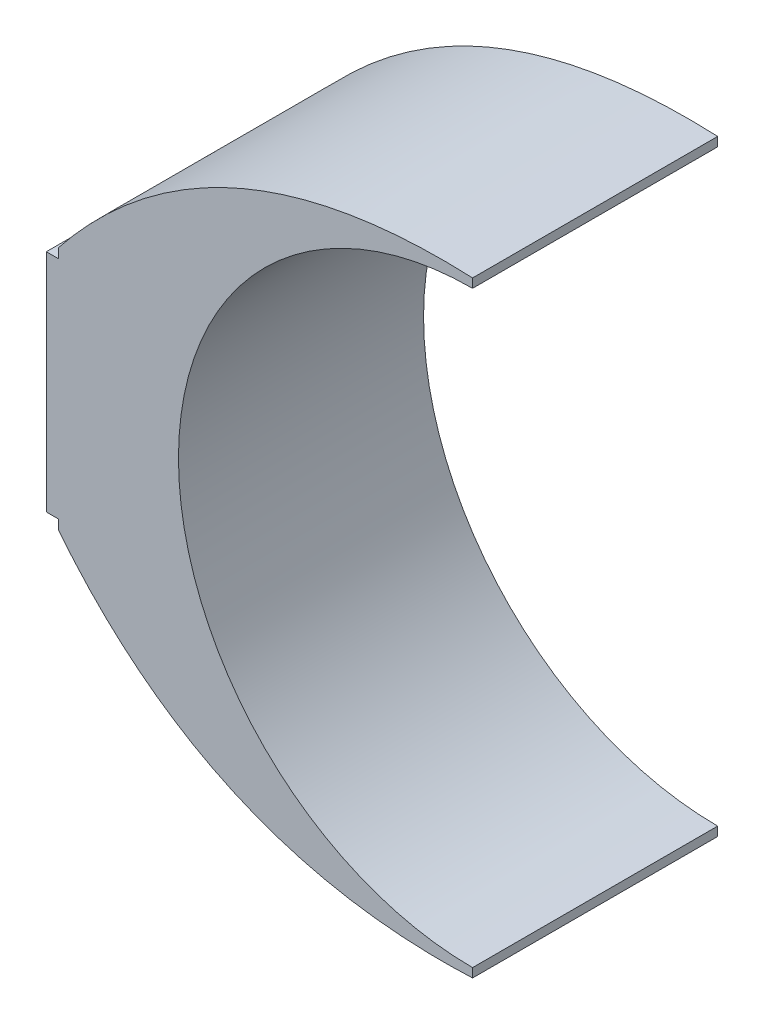
from build123d import *

# Parameters (mm, degrees)
BOSS_EXTRUDE1_DEPTH = 2


with BuildPart() as part:
    # Sketch1 → Boss-Extrude1 (new body)
    with BuildSketch(Plane.XY):
        with BuildLine():
            Line((4.115026411, 2.177343501), (4.115026411, 2.103740104))
            ThreePointArc((4.115026411, 2.103740104), (1.715026411, -0.296259896), (4.115026411, -2.696259896))
            Line((4.115026411, -2.696259896), (4.115026411, -2.769863293))
            add(Edge.make_bspline(
                [(4.115026411, -2.769863293), (1.986645095, -2.865928164), (0.736711976, -1.295422853)],
                knots=[0, 0, 0, 1, 1, 1], degree=2))
            Line((0.736711976, -1.295422853), (0.736711976, -1.215894452))
            Line((0.736711976, -1.215894452), (0.636711976, -1.215894452))
            Line((0.636711976, -1.215894452), (0.636711976, 0.62337466))
            Line((0.636711976, 0.62337466), (0.736711976, 0.62337466))
            Line((0.736711976, 0.62337466), (0.736711976, 0.70290306))
            add(Edge.make_bspline(
                [(4.115026411, 2.177343501), (1.986645095, 2.273408372), (0.736711976, 0.70290306)],
                knots=[0, 0, 0, 1, 1, 1], degree=2))
        make_face()
    extrude(amount=BOSS_EXTRUDE1_DEPTH)


solid = part.part
